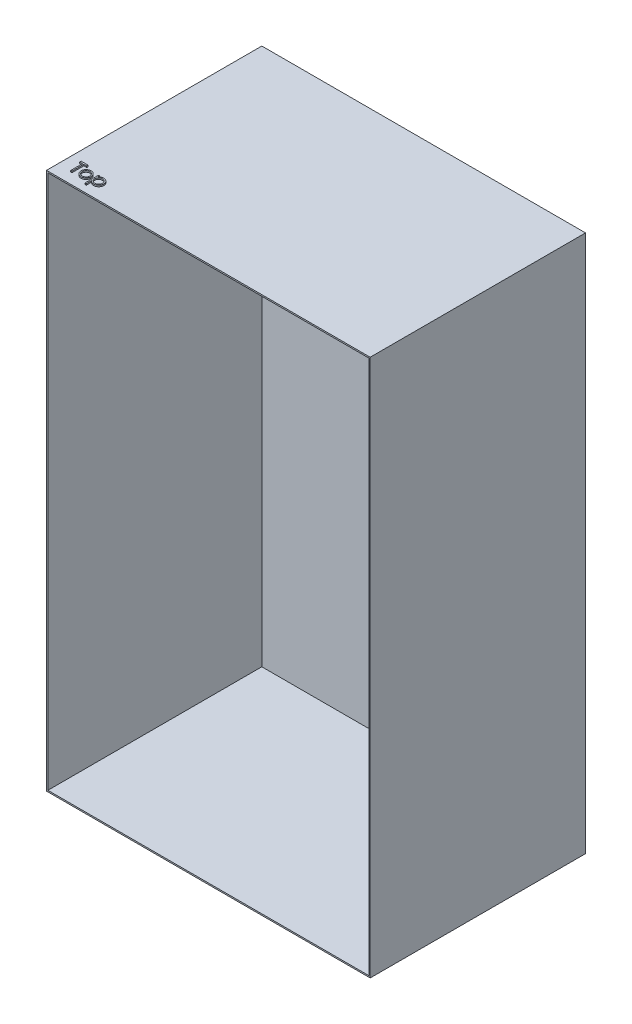
from build123d import *

# Parameters (mm, degrees)
SKETCH1_W           = 461.2
SKETCH1_H           = 766
BOSS_EXTRUDE1_DEPTH = 2
SKETCH1_6_W         = 461.2
SKETCH1_6_H         = 766
SKETCH1_6_W_2       = 457.2
SKETCH1_6_H_2       = 762
BOSS_EXTRUDE4_DEPTH = 304.8
BOSS_EXTRUDE5_DEPTH = 2


with BuildPart() as part:
    # Sketch1 → Boss-Extrude1 (new body)
    with BuildSketch(Plane.XY):
        Rectangle(SKETCH1_W, SKETCH1_H)
    extrude(amount=-BOSS_EXTRUDE1_DEPTH)

    # Sketch1_6 → Boss-Extrude4 (add)
    with BuildSketch(Plane.XY):
        Rectangle(SKETCH1_6_W, SKETCH1_6_H)
        Rectangle(SKETCH1_6_W_2, SKETCH1_6_H_2, mode=Mode.SUBTRACT)
    extrude(amount=BOSS_EXTRUDE4_DEPTH)

    # Sketch4 → Boss-Extrude5 (add)
    # profile 1 of 3: a face of its own
    with BuildSketch(Plane(origin=(0, 383, 0), x_dir=(1, 0, 0), z_dir=(0, 1, 0))):
        Polygon((-215.355769231, -272.703846154), (-215.355769231, -270.75), (-205.342307692, -270.75), (-205.342307692, -272.703846154), (-209.494230769, -272.703846154), (-209.494230769, -289.8), (-211.203846154, -289.8), (-211.203846154, -272.703846154), align=None)
    # profile 2 of 3: a face of its own
    with BuildSketch(Plane(origin=(0, 383, 0), x_dir=(1, 0, 0), z_dir=(0, 1, 0))):
        with BuildLine():
            add(Edge.make_bspline(
                [(-196.176021635, -275.634615385), (-195.914811992, -275.640177392), (-195.402643721, -275.651083129), (-194.652575085, -275.767641728), (-193.936593702, -275.945880954), (-193.251957427, -276.192287599), (-192.607434448, -276.522570787), (-191.993636676, -276.916684215), (-191.412246956, -277.383586617), (-191.063778754, -277.744764103), (-190.886899038, -277.928094952)],
                knots=[0, 0, 0, 0, 1.054011418, 2.066658804, 3.057071809, 4.030435133, 4.997543892, 5.974964718, 6.972108034, 8, 8, 8, 8], degree=3))
            add(Edge.make_bspline(
                [(-190.886899038, -277.928094952), (-190.73459726, -278.103431075), (-190.432941162, -278.450710083), (-190.046140607, -279.013804205), (-189.712920401, -279.596952467), (-189.445877713, -280.20789863), (-189.235320655, -280.841309341), (-189.085828794, -281.499361716), (-188.996909191, -282.180602491), (-188.984918757, -282.643266238), (-188.978846154, -282.877584135)],
                knots=[0, 0, 0, 0, 1.025258237, 2.030674902, 3.01204498, 3.988269485, 4.97094183, 5.956517959, 6.965070386, 8, 8, 8, 8], degree=3))
            add(Edge.make_bspline(
                [(-188.978846154, -282.877584135), (-188.984187433, -283.113260163), (-188.994742049, -283.578966986), (-189.094583732, -284.264872391), (-189.249874357, -284.929961354), (-189.472116219, -285.571449387), (-189.757093928, -286.191297348), (-190.104841813, -286.786797895), (-190.517800186, -287.359125935), (-190.985907654, -287.903421654), (-191.503261437, -288.405069195), (-192.064507902, -288.84228449), (-192.658617714, -289.216870216), (-193.293490823, -289.518602707), (-193.963329572, -289.756508361), (-194.669578757, -289.923604165), (-195.411141211, -290.024632758), (-195.917475088, -290.037606207), (-196.176021635, -290.044230769)],
                knots=[0, 0, 0, 0, 0.998656419, 1.973391657, 2.932242238, 3.890759089, 4.846373663, 5.82037756, 6.809684879, 7.83454468, 8.860553229, 9.859544525, 10.845671541, 11.83227036, 12.833544569, 13.85385346, 14.904124723, 16, 16, 16, 16], degree=3))
            add(Edge.make_bspline(
                [(-196.176021635, -290.044230769), (-196.435834894, -290.037583973), (-196.944692287, -290.024565886), (-197.688872275, -289.923996676), (-198.396387201, -289.75658537), (-199.067102858, -289.517820874), (-199.704705525, -289.216860572), (-200.302257744, -288.843416947), (-200.863960142, -288.404939531), (-201.381423371, -287.903456788), (-201.849501494, -287.359116883), (-202.26246744, -286.786800244), (-202.610213358, -286.191296736), (-202.895191582, -285.571449551), (-203.117433306, -284.929961311), (-203.272723968, -284.264872403), (-203.372565642, -283.578966983), (-203.383120259, -283.113260162), (-203.388461538, -282.877584135)],
                knots=[0, 0, 0, 0, 1.099876186, 2.154163076, 3.173186993, 4.173200201, 5.163417411, 6.152872554, 7.150605724, 8.17532212, 9.198891216, 10.186952605, 11.159729845, 12.11414092, 13.071450619, 14.029093627, 15.002601286, 16, 16, 16, 16], degree=3))
            add(Edge.make_bspline(
                [(-203.388461538, -282.877584135), (-203.382347521, -282.644539792), (-203.370242816, -282.183152045), (-203.281412617, -281.5031919), (-203.132503902, -280.846253254), (-202.921694444, -280.215287449), (-202.652190334, -279.607018576), (-202.323652467, -279.022429424), (-201.93290631, -278.461881539), (-201.632449973, -278.11505136), (-201.480408654, -277.939543269)],
                knots=[0, 0, 0, 0, 1.031353054, 2.041901799, 3.029428768, 4.008703097, 4.981709435, 5.96992636, 6.972712378, 8, 8, 8, 8], degree=3))
            add(Edge.make_bspline(
                [(-201.480408654, -277.939543269), (-201.303795608, -277.754622528), (-200.956454978, -277.390943353), (-200.372171189, -276.925402044), (-199.759883391, -276.523087413), (-199.108237721, -276.199366869), (-198.42416388, -275.944431508), (-197.704513432, -275.767182062), (-196.951899555, -275.651503087), (-196.437225045, -275.640300719), (-196.176021635, -275.634615385)],
                knots=[0, 0, 0, 0, 1.027980169, 2.021703884, 2.998553061, 3.971491411, 4.943284454, 5.930300938, 6.949603206, 8, 8, 8, 8], degree=3))
        make_face()
        with BuildLine():
            add(Edge.make_bspline(
                [(-196.183653846, -277.344230769), (-196.368371416, -277.349480904), (-196.733038102, -277.359845642), (-197.269810413, -277.438679466), (-197.786556108, -277.563579453), (-198.28425556, -277.741038673), (-198.761230398, -277.970176966), (-199.217937289, -278.251618183), (-199.655719569, -278.581634704), (-200.066013371, -278.959710102), (-200.442562813, -279.372708629), (-200.7717358, -279.812754697), (-201.051635307, -280.272710667), (-201.284808172, -280.753054845), (-201.458474439, -281.258654984), (-201.58460189, -281.783785277), (-201.663361341, -282.329515615), (-201.673628631, -282.7005063), (-201.678846154, -282.889032452)],
                knots=[0, 0, 0, 0, 1.021534396, 2.016698045, 2.994645724, 3.958388632, 4.93408049, 5.916473867, 6.921342795, 7.962252576, 8.998418191, 10.008913653, 10.997312074, 11.973003931, 12.956656626, 13.948281152, 14.957379055, 16, 16, 16, 16], degree=3))
            add(Edge.make_bspline(
                [(-201.678846154, -282.889032452), (-201.670100442, -283.132611343), (-201.65274184, -283.616069893), (-201.511580054, -284.328056146), (-201.27543473, -285.011580227), (-200.956552536, -285.662635128), (-200.557012975, -286.265008527), (-200.086276226, -286.80206332), (-199.549394428, -287.265717523), (-198.952767477, -287.650423268), (-198.308581833, -287.956092795), (-197.626829571, -288.172712934), (-196.915770936, -288.31352886), (-196.429828671, -288.327525028), (-196.183653846, -288.334615385)],
                knots=[0, 0, 0, 0, 1.016792936, 2.018143844, 3.017858371, 4.030088057, 5.03801393, 6.028138512, 7.003788237, 7.991172063, 8.984598303, 9.972568034, 10.972917682, 12, 12, 12, 12], degree=3))
            add(Edge.make_bspline(
                [(-196.183653846, -288.334615385), (-195.937493181, -288.327483716), (-195.451578866, -288.313406001), (-194.741508203, -288.17342214), (-194.061619299, -287.955143643), (-193.418102747, -287.650767044), (-192.821747377, -287.264256615), (-192.281004302, -286.804681477), (-191.814286862, -286.263586086), (-191.415142527, -285.661837251), (-191.091038113, -285.012589563), (-190.855998114, -284.327929992), (-190.714496968, -283.616102021), (-190.697184172, -283.132622107), (-190.688461538, -282.889032452)],
                knots=[0, 0, 0, 0, 1.02726834, 2.027799167, 3.010890988, 4.004497153, 4.992059811, 5.971914811, 6.958719428, 7.966827853, 8.981595046, 9.981490638, 10.983022906, 12, 12, 12, 12], degree=3))
            add(Edge.make_bspline(
                [(-190.688461538, -282.889032452), (-190.693677265, -282.700505174), (-190.70394102, -282.329512271), (-190.782726183, -281.783798059), (-190.908758477, -281.258608083), (-191.082775423, -280.753227894), (-191.314935127, -280.271466978), (-191.600232243, -279.814105178), (-191.92806111, -279.371184263), (-192.309154297, -278.961045161), (-192.719019825, -278.581487319), (-193.156979533, -278.251490214), (-193.613009202, -277.971413872), (-194.088598345, -277.739078763), (-194.586361606, -277.565193953), (-195.102383266, -277.437958288), (-195.63686536, -277.360178789), (-196.000225295, -277.349580776), (-196.183653846, -277.344230769)],
                knots=[0, 0, 0, 0, 1.042956736, 2.052379634, 3.044323526, 4.02829302, 5.004299113, 5.996692471, 7.007513377, 8.048758398, 9.090003419, 10.095195979, 11.07790575, 12.047570684, 13.018257071, 13.989683339, 14.985167495, 16, 16, 16, 16], degree=3))
        make_face(mode=Mode.SUBTRACT)
    # profile 3 of 3: a face of its own
    with BuildSketch(Plane(origin=(0, 383, 0), x_dir=(1, 0, 0), z_dir=(0, 1, 0))):
        with BuildLine():
            Line((-185.559615385, -275.878846154), (-183.85, -275.878846154))
            Line((-183.85, -275.878846154), (-183.85, -278.454717548))
            add(Edge.make_bspline(
                [(-183.85, -278.454717548), (-183.66843998, -278.221013597), (-183.315614414, -277.766856737), (-182.707511718, -277.179081894), (-182.065652944, -276.683372027), (-181.373520655, -276.294847098), (-180.641871714, -276.001908107), (-179.873708672, -275.785394244), (-179.062511966, -275.657805647), (-178.507904131, -275.642447748), (-178.225060096, -275.634615385)],
                knots=[0, 0, 0, 0, 1.0828784, 2.104357462, 3.088488658, 4.04616522, 5.001424249, 5.969181776, 6.964304535, 8, 8, 8, 8], degree=3))
            add(Edge.make_bspline(
                [(-178.225060096, -275.634615385), (-177.978000084, -275.64176283), (-177.489672992, -275.65589013), (-176.770871704, -275.751537756), (-176.078674259, -275.915464053), (-175.416996708, -276.151689036), (-174.778750596, -276.443728093), (-174.173384596, -276.812302244), (-173.591469386, -277.23905594), (-173.047639842, -277.730176646), (-172.545147827, -278.261553354), (-172.11055647, -278.833174752), (-171.735696534, -279.426242544), (-171.432691063, -280.049950931), (-171.195337058, -280.699388454), (-171.026528598, -281.377178968), (-170.926066281, -282.080809444), (-170.912587309, -282.559251394), (-170.905769231, -282.801262019)],
                knots=[0, 0, 0, 0, 1.041296284, 2.058176809, 3.050446431, 4.034000596, 5.01514041, 6.003636468, 7.015969324, 8.052561599, 9.08815499, 10.094063707, 11.074456064, 12.040834395, 13.011057502, 13.983766392, 14.980127149, 16, 16, 16, 16], degree=3))
            add(Edge.make_bspline(
                [(-170.905769231, -282.801262019), (-170.912439374, -283.048380299), (-170.925593858, -283.535733207), (-171.027620247, -284.251398694), (-171.190671234, -284.9398514), (-171.425030773, -285.59994622), (-171.727879446, -286.231228665), (-172.096385696, -286.833243478), (-172.531196324, -287.405797776), (-173.028135319, -287.941118561), (-173.567266299, -288.434237679), (-174.143542349, -288.865519172), (-174.748020215, -289.227694372), (-175.377607297, -289.53022448), (-176.037693272, -289.758237653), (-176.725198398, -289.922708825), (-177.439748366, -290.024133724), (-177.925801779, -290.037480385), (-178.171634615, -290.044230769)],
                knots=[0, 0, 0, 0, 1.038740735, 2.04854663, 3.033179607, 4.009277356, 4.987731542, 5.972001279, 6.972200261, 8.005528982, 9.039189865, 10.040446548, 11.026516639, 11.997840187, 12.972163198, 13.956796175, 14.96660207, 16, 16, 16, 16], degree=3))
            add(Edge.make_bspline(
                [(-178.171634615, -290.044230769), (-178.448281828, -290.037183316), (-178.994741181, -290.023262529), (-179.79373993, -289.882186883), (-180.562689652, -289.671347276), (-181.293071141, -289.362742754), (-181.990670235, -288.969466303), (-182.651540892, -288.489895039), (-183.279193504, -287.925031924), (-183.656975455, -287.496505896), (-183.85, -287.277554087)],
                knots=[0, 0, 0, 0, 1.014726462, 2.004382257, 2.969841629, 3.936926163, 4.907207904, 5.903978561, 6.929055279, 8, 8, 8, 8], degree=3))
            Line((-183.85, -287.277554087), (-183.85, -294.928846154))
            Line((-183.85, -294.928846154), (-185.559615385, -294.928846154))
            Line((-185.559615385, -294.928846154), (-185.559615385, -275.878846154))
        make_face()
        with BuildLine():
            add(Edge.make_bspline(
                [(-178.240324519, -277.344230769), (-178.433978995, -277.347715603), (-178.815234743, -277.354576343), (-179.374064963, -277.436077407), (-179.912338649, -277.554392827), (-180.424630984, -277.733527598), (-180.915852197, -277.953412567), (-181.382218865, -278.228178943), (-181.823403625, -278.552856289), (-182.238296462, -278.921225289), (-182.613109531, -279.327124663), (-182.944922039, -279.760309738), (-183.223636085, -280.220231927), (-183.45496851, -280.702607114), (-183.631008377, -281.211216452), (-183.75595308, -281.743163278), (-183.834495429, -282.299029827), (-183.844776645, -282.677613234), (-183.85, -282.869951923)],
                knots=[0, 0, 0, 0, 1.05670511, 2.080379991, 3.077984906, 4.06214886, 5.038337365, 6.01289324, 7.01187578, 8.025460281, 9.038092164, 10.024533457, 11.000252242, 11.969694649, 12.940728589, 13.933144304, 14.949937299, 16, 16, 16, 16], degree=3))
            add(Edge.make_bspline(
                [(-183.85, -282.869951923), (-183.841341198, -283.122435793), (-183.82437787, -283.617073077), (-183.686470196, -284.339798083), (-183.462032544, -285.023702094), (-183.143469117, -285.663025738), (-182.740983034, -286.250760884), (-182.256034497, -286.777034042), (-181.69301147, -287.238537116), (-181.061274326, -287.627272797), (-180.384062444, -287.942893558), (-179.677656265, -288.168849475), (-178.951770271, -288.308035461), (-178.460996988, -288.325707433), (-178.213611779, -288.334615385)],
                knots=[0, 0, 0, 0, 1.03728447, 2.032128127, 3.01272805, 3.987917167, 4.958271349, 5.931593992, 6.91984656, 7.941419022, 8.973179163, 9.983609215, 10.983593296, 12, 12, 12, 12], degree=3))
            add(Edge.make_bspline(
                [(-178.213611779, -288.334615385), (-177.971209956, -288.326144248), (-177.490085916, -288.309330564), (-176.781653855, -288.163798428), (-176.09318338, -287.941484795), (-175.43905987, -287.617310637), (-174.824977743, -287.220036179), (-174.270451002, -286.743459427), (-173.785999087, -286.191064164), (-173.37308024, -285.575975027), (-173.040350298, -284.916434725), (-172.790358564, -284.234001738), (-172.646076187, -283.53108165), (-172.625628523, -283.057565527), (-172.615384615, -282.820342548)],
                knots=[0, 0, 0, 0, 1.00104056, 1.986885549, 2.97790532, 3.984399681, 4.995088187, 5.994304198, 6.996462723, 8.023150851, 9.048424203, 10.043036403, 11.019596776, 12, 12, 12, 12], degree=3))
            add(Edge.make_bspline(
                [(-172.615384615, -282.820342548), (-172.623302524, -282.581646107), (-172.639076652, -282.106112912), (-172.7944541, -281.405274825), (-173.02795255, -280.720084556), (-173.368452533, -280.069551278), (-173.772319443, -279.455738056), (-174.260799526, -278.913880515), (-174.80843911, -278.439422996), (-175.421790131, -278.047453408), (-176.080051589, -277.735656643), (-176.773008489, -277.50768998), (-177.49714581, -277.370672858), (-177.990419187, -277.35312233), (-178.240324519, -277.344230769)],
                knots=[0, 0, 0, 0, 0.983928682, 1.960191568, 2.949917689, 3.96440592, 4.982380491, 5.975291189, 6.965713506, 7.964880129, 8.970154049, 9.96478489, 10.968906225, 12, 12, 12, 12], degree=3))
        make_face(mode=Mode.SUBTRACT)
    extrude(amount=BOSS_EXTRUDE5_DEPTH)


solid = part.part
